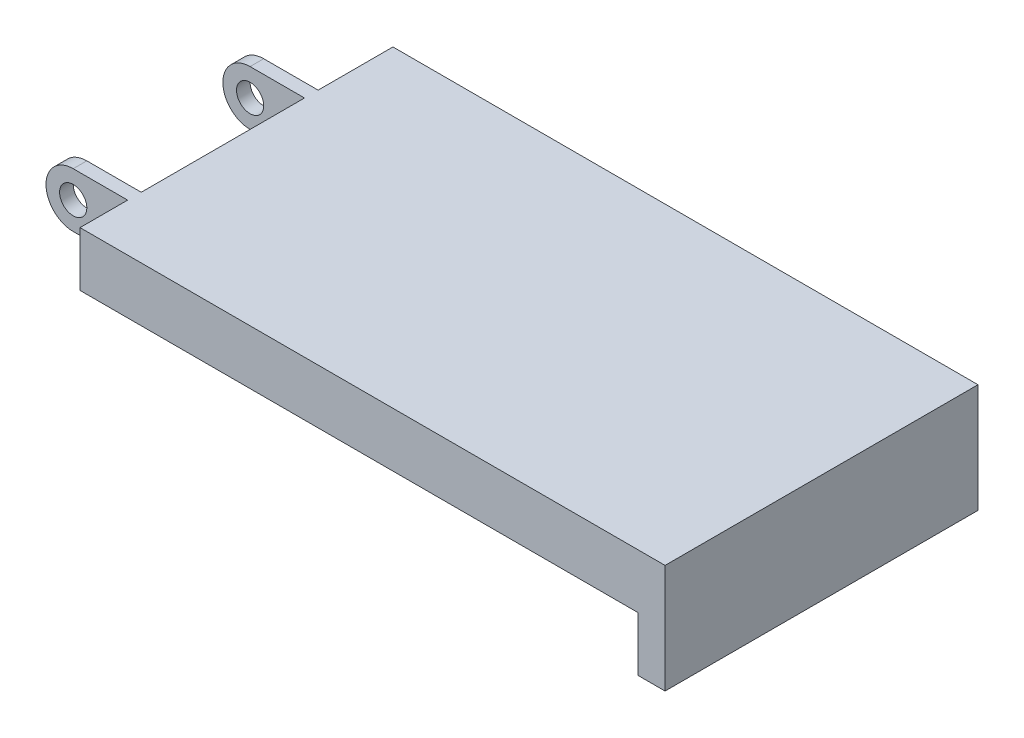
from build123d import *

# Parameters (mm, degrees)
SKETCH_1_R           = 1
EXTRUDE_1_DEPTH      = 24
SKETCH_2_W           = 8
SKETCH_2_H           = 4
CUT_EXTRUDE_2_DEPTH  = 4
CUT_EXTRUDE_3_DEPTH  = 6
CUT_EXTRUDE_START    = -7
CUT_EXTRUDE_4_DEPTH  = 12
SKETCH_4_W           = 2
SKETCH_4_H           = 1
EXTRUDE_2_DEPTH      = 0.5
CUT_EXTRUDE_21_DEPTH = 0.5
CUT_EXTRUDE_22_DEPTH = 0.5


with BuildPart() as part:
    # 草图1 → 凸台-拉伸1 (new body)
    with BuildSketch(Plane.XY):
        with BuildLine():
            Line((0, 2), (47, 2))
            Line((47, 2), (47, -6))
            Line((47, -6), (45, -6))
            Line((45, -6), (45, -2))
            Line((45, -2), (0, -2))
            ThreePointArc((0, -2), (-2, 0), (0, 2))
        make_face()
        Circle(SKETCH_1_R, mode=Mode.SUBTRACT)
    extrude(amount=EXTRUDE_1_DEPTH)

    # 草图2 → 切除-拉伸2 (cut)
    with BuildSketch(Plane.XY.offset(24)):
        Rectangle(SKETCH_2_W, SKETCH_2_H)
    extrude(amount=-CUT_EXTRUDE_2_DEPTH, mode=Mode.SUBTRACT)

    # 草图3 → 切除-拉伸3 (cut)
    with BuildSketch(Plane(origin=(0, 0, 0), x_dir=(-1, 0, 0), z_dir=(0, 0, -1))):
        with BuildLine():
            Line((0, 2), (-4, 2))
            Line((-4, 2), (-4, -2))
            Line((-4, -2), (0, -2))
            ThreePointArc((0, -2), (2, 0), (0, 2))
        make_face()
    extrude(amount=-CUT_EXTRUDE_3_DEPTH, mode=Mode.SUBTRACT)

    # 草图3<2> → 切除-拉伸4 (cut)
    with BuildSketch(Plane(origin=(0, 0, 0), x_dir=(-1, 0, 0), z_dir=(0, 0, -1)).offset(CUT_EXTRUDE_START)):
        with BuildLine():
            ThreePointArc((0, -2), (2, 0), (0, 2))
            Line((0, 2), (-4, 2))
            Line((-4, 2), (-4, -2))
            Line((-4, -2), (0, -2))
        make_face()
    extrude(amount=-CUT_EXTRUDE_4_DEPTH, mode=Mode.SUBTRACT)

    # 草图4 → 凸台-拉伸2 (add)
    with BuildSketch(Plane.ZY.offset(-45)):
        with Locations((12, -5.5)):
            Rectangle(SKETCH_4_W, SKETCH_4_H)
    extrude(amount=EXTRUDE_2_DEPTH)

    # 草图5 → 切除-拉伸21 (cut)
    with BuildSketch(Plane.XY):
        Polygon((4, 2), (4, -2), (45, -2), (45, -6), (47, -6), (47, 2), align=None)
    extrude(amount=CUT_EXTRUDE_21_DEPTH, mode=Mode.SUBTRACT)

    # 草图6 → 切除-拉伸22 (cut)
    with BuildSketch(Plane.XY.offset(24)):
        Polygon((4, -2), (45, -2), (45, -6), (47, -6), (47, 2), (4, 2), align=None)
    extrude(amount=-CUT_EXTRUDE_22_DEPTH, mode=Mode.SUBTRACT)


solid = part.part
